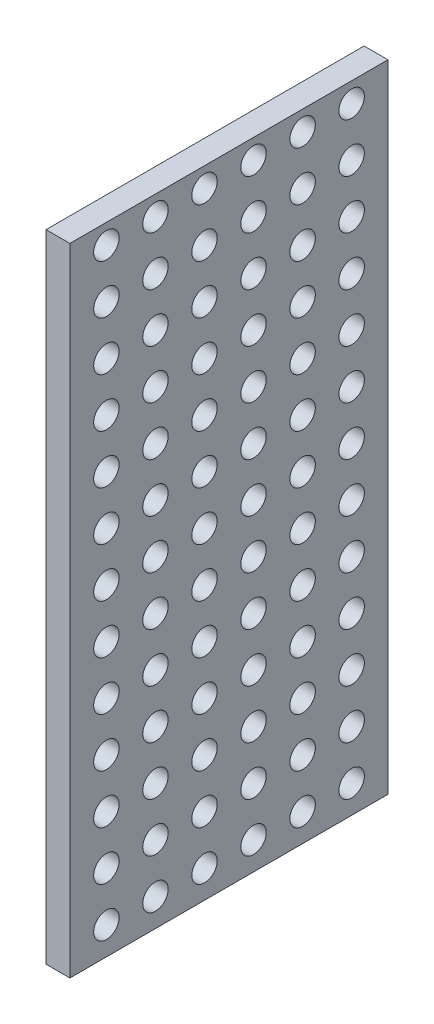
from build123d import *

# Parameters (mm, degrees)
SKETCH1_W           = 50
SKETCH1_H           = 100
BOSS_EXTRUDE1_DEPTH = 3.75
SKETCH2_R           = 2
CUT_EXTRUDE1_DEPTH  = 3.75
SKETCH5_R           = 1.2
CUT_EXTRUDE2_DEPTH  = 1.875


with BuildPart() as part:
    # Sketch1 → Boss-Extrude1 (new body)
    with BuildSketch(Plane(origin=(0, 0, 0), x_dir=(0, 0, -1), z_dir=(1, 0, 0))):
        Rectangle(SKETCH1_W, SKETCH1_H)
    extrude(amount=BOSS_EXTRUDE1_DEPTH)

    # Sketch2 → Cut-Extrude1 (cut)
    with BuildSketch(Plane.ZY):
        with Locations((-19.29, 46.895)):
            Circle(SKETCH2_R)
        with Locations((-11.58, 46.895)):
            Circle(SKETCH2_R)
        with Locations((-3.87, 46.895)):
            Circle(SKETCH2_R)
        with Locations((3.84, 46.895)):
            Circle(SKETCH2_R)
        with Locations((11.55, 46.895)):
            Circle(SKETCH2_R)
        with Locations((19.26, 46.895)):
            Circle(SKETCH2_R)
        with Locations((-19.29, 39.185)):
            Circle(SKETCH2_R)
        with Locations((-11.58, 39.185)):
            Circle(SKETCH2_R)
        with Locations((-3.87, 39.185)):
            Circle(SKETCH2_R)
        with Locations((3.84, 39.185)):
            Circle(SKETCH2_R)
        with Locations((11.55, 39.185)):
            Circle(SKETCH2_R)
        with Locations((19.26, 39.185)):
            Circle(SKETCH2_R)
        with Locations((-19.29, 31.475)):
            Circle(SKETCH2_R)
        with Locations((-11.58, 31.475)):
            Circle(SKETCH2_R)
        with Locations((-3.87, 31.475)):
            Circle(SKETCH2_R)
        with Locations((3.84, 31.475)):
            Circle(SKETCH2_R)
        with Locations((11.55, 31.475)):
            Circle(SKETCH2_R)
        with Locations((19.26, 31.475)):
            Circle(SKETCH2_R)
        with Locations((-19.29, 23.765)):
            Circle(SKETCH2_R)
        with Locations((-11.58, 23.765)):
            Circle(SKETCH2_R)
        with Locations((-3.87, 23.765)):
            Circle(SKETCH2_R)
        with Locations((3.84, 23.765)):
            Circle(SKETCH2_R)
        with Locations((11.55, 23.765)):
            Circle(SKETCH2_R)
        with Locations((19.26, 23.765)):
            Circle(SKETCH2_R)
        with Locations((-19.29, 16.055)):
            Circle(SKETCH2_R)
        with Locations((-11.58, 16.055)):
            Circle(SKETCH2_R)
        with Locations((-3.87, 16.055)):
            Circle(SKETCH2_R)
        with Locations((3.84, 16.055)):
            Circle(SKETCH2_R)
        with Locations((11.55, 16.055)):
            Circle(SKETCH2_R)
        with Locations((19.26, 16.055)):
            Circle(SKETCH2_R)
        with Locations((-19.29, 8.345)):
            Circle(SKETCH2_R)
        with Locations((-11.58, 8.345)):
            Circle(SKETCH2_R)
        with Locations((-3.87, 8.345)):
            Circle(SKETCH2_R)
        with Locations((3.84, 8.345)):
            Circle(SKETCH2_R)
        with Locations((11.55, 8.345)):
            Circle(SKETCH2_R)
        with Locations((19.26, 8.345)):
            Circle(SKETCH2_R)
        with Locations((-19.29, 0.635)):
            Circle(SKETCH2_R)
        with Locations((-11.58, 0.635)):
            Circle(SKETCH2_R)
        with Locations((-3.87, 0.635)):
            Circle(SKETCH2_R)
        with Locations((3.84, 0.635)):
            Circle(SKETCH2_R)
        with Locations((11.55, 0.635)):
            Circle(SKETCH2_R)
        with Locations((19.26, 0.635)):
            Circle(SKETCH2_R)
        with Locations((-19.29, -7.075)):
            Circle(SKETCH2_R)
        with Locations((-11.58, -7.075)):
            Circle(SKETCH2_R)
        with Locations((-3.87, -7.075)):
            Circle(SKETCH2_R)
        with Locations((3.84, -7.075)):
            Circle(SKETCH2_R)
        with Locations((11.55, -7.075)):
            Circle(SKETCH2_R)
        with Locations((19.26, -7.075)):
            Circle(SKETCH2_R)
        with Locations((-19.29, -14.785)):
            Circle(SKETCH2_R)
        with Locations((-11.58, -14.785)):
            Circle(SKETCH2_R)
        with Locations((-3.87, -14.785)):
            Circle(SKETCH2_R)
        with Locations((3.84, -14.785)):
            Circle(SKETCH2_R)
        with Locations((11.55, -14.785)):
            Circle(SKETCH2_R)
        with Locations((19.26, -14.785)):
            Circle(SKETCH2_R)
        with Locations((-19.29, -22.495)):
            Circle(SKETCH2_R)
        with Locations((-11.58, -22.495)):
            Circle(SKETCH2_R)
        with Locations((-3.87, -22.495)):
            Circle(SKETCH2_R)
        with Locations((3.84, -22.495)):
            Circle(SKETCH2_R)
        with Locations((11.55, -22.495)):
            Circle(SKETCH2_R)
        with Locations((19.26, -22.495)):
            Circle(SKETCH2_R)
        with Locations((-19.29, -30.205)):
            Circle(SKETCH2_R)
        with Locations((-11.58, -30.205)):
            Circle(SKETCH2_R)
        with Locations((-3.87, -30.205)):
            Circle(SKETCH2_R)
        with Locations((3.84, -30.205)):
            Circle(SKETCH2_R)
        with Locations((11.55, -30.205)):
            Circle(SKETCH2_R)
        with Locations((19.26, -30.205)):
            Circle(SKETCH2_R)
        with Locations((-19.29, -37.915)):
            Circle(SKETCH2_R)
        with Locations((-11.58, -37.915)):
            Circle(SKETCH2_R)
        with Locations((-3.87, -37.915)):
            Circle(SKETCH2_R)
        with Locations((3.84, -37.915)):
            Circle(SKETCH2_R)
        with Locations((11.55, -37.915)):
            Circle(SKETCH2_R)
        with Locations((19.26, -37.915)):
            Circle(SKETCH2_R)
        with Locations((-19.29, -45.625)):
            Circle(SKETCH2_R)
        with Locations((-11.58, -45.625)):
            Circle(SKETCH2_R)
        with Locations((-3.87, -45.625)):
            Circle(SKETCH2_R)
        with Locations((3.84, -45.625)):
            Circle(SKETCH2_R)
        with Locations((11.55, -45.625)):
            Circle(SKETCH2_R)
        with Locations((19.26, -45.625)):
            Circle(SKETCH2_R)
    extrude(amount=-CUT_EXTRUDE1_DEPTH, mode=Mode.SUBTRACT)

    # Sketch5 → Cut-Extrude2 (cut)
    with BuildSketch(Plane(origin=(0, 0, -25), x_dir=(-1, 0, 0), z_dir=(0, 0, -1))):
        with Locations((-1.875, 4)):
            Circle(SKETCH5_R)
        with Locations((-1.875, -45)):
            Circle(SKETCH5_R)
    extrude(amount=-CUT_EXTRUDE2_DEPTH, mode=Mode.SUBTRACT)


solid = part.part
